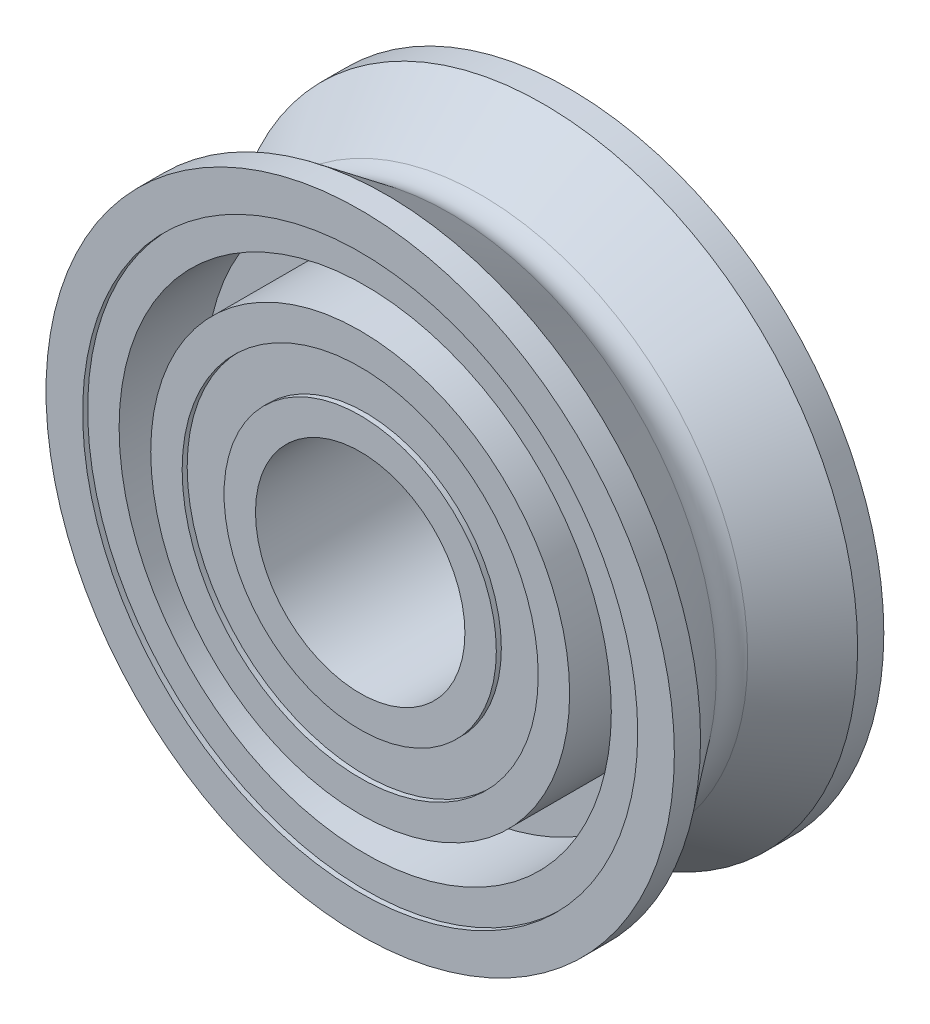
from build123d import *


with BuildPart() as part:
    # Sketch1 → Revolve1 (revolve)
    with BuildSketch(Plane(origin=(0, 0, 0), x_dir=(0, 0, -1), z_dir=(1, 0, 0))):
        with BuildLine():
            Line((1.190625, 4.7625), (1.5875, 4.7625))
            Line((1.5875, 4.7625), (1.5875, 4.206875))
            Line((1.5875, 4.206875), (1.5113, 4.206875))
            Line((1.5113, 4.206875), (1.5113, 3.730625))
            Line((1.5113, 3.730625), (0.1984375, 3.730625))
            Line((0.1984375, 3.730625), (0.1984375, 3.175))
            Line((0.1984375, 3.175), (1.5875, 3.175))
            Line((1.5875, 3.175), (1.5875, 2.69875))
            Line((1.5875, 2.69875), (1.5113, 2.69875))
            Line((1.5113, 2.69875), (1.5113, 2.06375))
            Line((1.5113, 2.06375), (1.5875, 2.06375))
            Line((1.5875, 2.06375), (1.5875, 1.5875))
            Line((1.5875, 1.5875), (-1.5875, 1.5875))
            Line((-1.5875, 1.5875), (-1.5875, 2.06375))
            Line((-1.5875, 2.06375), (-1.5113, 2.06375))
            Line((-1.5113, 2.06375), (-1.5113, 2.69875))
            Line((-1.5113, 2.69875), (-1.5875, 2.69875))
            Line((-1.5875, 2.69875), (-1.5875, 3.175))
            Line((-1.5875, 3.175), (-0.1984375, 3.175))
            Line((-0.1984375, 3.175), (-0.1984375, 3.730625))
            Line((-0.1984375, 3.730625), (-1.5113, 3.730625))
            Line((-1.5113, 3.730625), (-1.5113, 4.206875))
            Line((-1.5113, 4.206875), (-1.5875, 4.206875))
            Line((-1.5875, 4.206875), (-1.5875, 4.7625))
            Line((-1.5875, 4.7625), (-1.190625, 4.7625))
            Line((-1.190625, 4.7625), (-0.238125, 4.048125))
            ThreePointArc((-0.238125, 4.048125), (0, 3.96875), (0.238125, 4.048125))
            Line((0.238125, 4.048125), (1.190625, 4.7625))
        make_face()
    revolve(axis=Axis((0, 0, 1.5875), (0, 0, -1)))


solid = part.part
